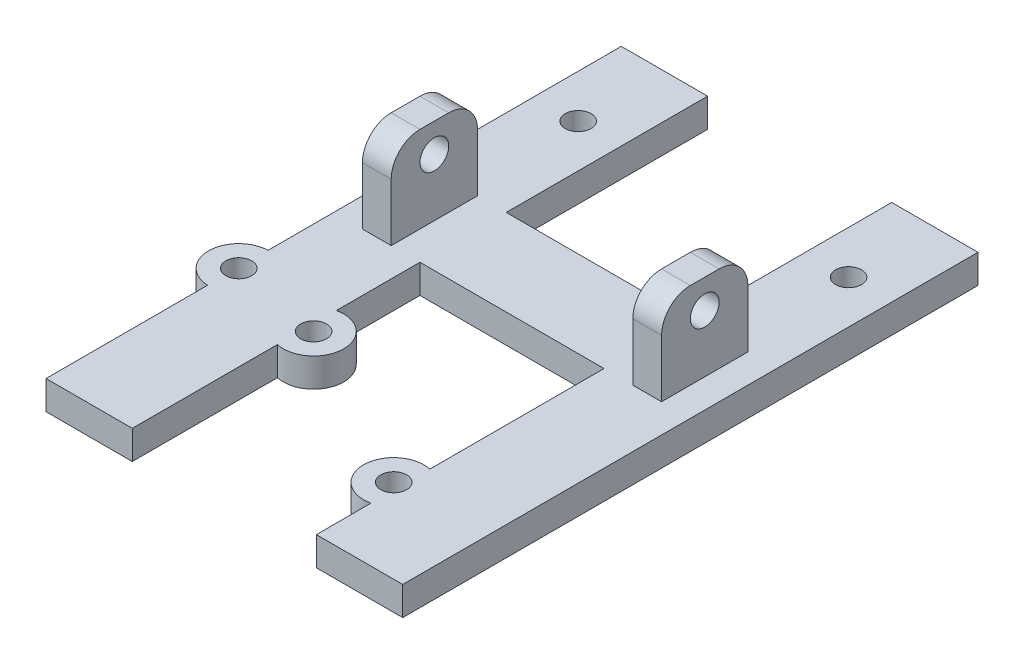
from build123d import *

# Parameters (mm, degrees)
SKETCH1_W           = 15
SKETCH1_H           = 100
SKETCH1_W_2         = 32
SKETCH1_H_2         = 15
BOSS_EXTRUDE1_DEPTH = 2.5
SKETCH2_W           = 5
SKETCH2_H           = 15
BOSS_EXTRUDE2_DEPTH = 15
SKETCH3_R           = 2.5
CUT_EXTRUDE1_DEPTH  = 52
FILLET2_R           = 5
BOSS_EXTRUDE3_DEPTH = 5
SKETCH5_R           = 2.25
CUT_EXTRUDE3_DEPTH  = 5
SKETCH6_R           = 2.25
CUT_EXTRUDE4_DEPTH  = 5


with BuildPart() as part:
    # Sketch1 → Boss-Extrude1 (new body, symmetric)
    with BuildSketch(Plane(origin=(0, 0, 0), x_dir=(1, 0, 0), z_dir=(0, 1, 0))):
        with Locations((7.5, 50)):
            Rectangle(SKETCH1_W, SKETCH1_H)
        with Locations((31, 57.5)):
            Rectangle(SKETCH1_W_2, SKETCH1_H_2)
        with Locations((54.5, 50)):
            Rectangle(SKETCH1_W, SKETCH1_H)
    extrude(amount=BOSS_EXTRUDE1_DEPTH, both=True)

    # Sketch2 → Boss-Extrude2 (add)
    with BuildSketch(Plane(origin=(0, 2.5, 0), x_dir=(1, 0, 0), z_dir=(0, 1, 0))):
        with Locations((54.5, 57.5)):
            Rectangle(SKETCH2_W, SKETCH2_H)
        with Locations((7.5, 57.5)):
            Rectangle(SKETCH2_W, SKETCH2_H)
    extrude(amount=BOSS_EXTRUDE2_DEPTH)

    # Sketch3 → Cut-Extrude1 (cut)
    with BuildSketch(Plane.ZY.offset(-5)):
        with Locations((-57.5, 12.5)):
            Circle(SKETCH3_R)
    extrude(amount=-CUT_EXTRUDE1_DEPTH, mode=Mode.SUBTRACT)

    # Fillet2
    fillet2_edges = [part.edges().sort_by_distance(p)[0] for p in [
        (54.5, 17.5, -65),
        (54.5, 17.5, -50),
        (7.5, 17.5, -65),
        (7.5, 17.5, -50),
    ]]
    fillet(fillet2_edges, radius=FILLET2_R)

    # Sketch4 → Boss-Extrude3 (add)
    with BuildSketch(Plane(origin=(0, 2.5, 0), x_dir=(1, 0, 0), z_dir=(0, 1, 0))):
        with BuildLine():
            ThreePointArc((47, 12.674737063), (43.587769422, 14.601319551), (47, 16.527902039))
            Line((47, 16.527902039), (47, 19.721057834))
            ThreePointArc((47, 19.721057834), (40.587769422, 14.601319551), (47, 9.481581269))
            Line((47, 9.481581269), (47, 12.674737063))
        make_face()
        with BuildLine():
            ThreePointArc((15, 25.231075416), (21.41, 30.351319551), (15, 35.471563686))
            Line((15, 35.471563686), (15, 32.279245898))
            ThreePointArc((15, 32.279245898), (17.26736173, 32.30995428), (18.41, 30.351319551))
            ThreePointArc((18.41, 30.351319551), (17.26736173, 28.392684823), (15, 28.423393204))
            Line((15, 28.423393204), (15, 25.231075416))
        make_face()
        with BuildLine():
            Line((0, 35.595623452), (0, 38.59888089))
            ThreePointArc((0, 38.59888089), (-5.09, 33.351319551), (0, 28.103758213))
            Line((0, 28.103758213), (0, 31.10701565))
            ThreePointArc((0, 31.10701565), (-2.09, 33.351319551), (0, 35.595623452))
        make_face()
    extrude(amount=-BOSS_EXTRUDE3_DEPTH)

    # Sketch5 → Cut-Extrude3 (cut)
    with BuildSketch(Plane(origin=(0, 2.5, 0), x_dir=(1, 0, 0), z_dir=(0, 1, 0))):
        with Locations((0.16, 33.351319551)):
            Circle(SKETCH5_R)
        with Locations((16.16, 30.351319551)):
            Circle(SKETCH5_R)
        with Locations((45.837769422, 14.601319551)):
            Circle(SKETCH5_R)
    extrude(amount=-CUT_EXTRUDE3_DEPTH, mode=Mode.SUBTRACT)

    # Sketch6 → Cut-Extrude4 (cut)
    with BuildSketch(Plane(origin=(0, 2.5, 0), x_dir=(1, 0, 0), z_dir=(0, 1, 0))):
        with Locations((7.5, 85)):
            Circle(SKETCH6_R)
        with Locations((54.5, 85)):
            Circle(SKETCH6_R)
    extrude(amount=-CUT_EXTRUDE4_DEPTH, mode=Mode.SUBTRACT)


solid = part.part
